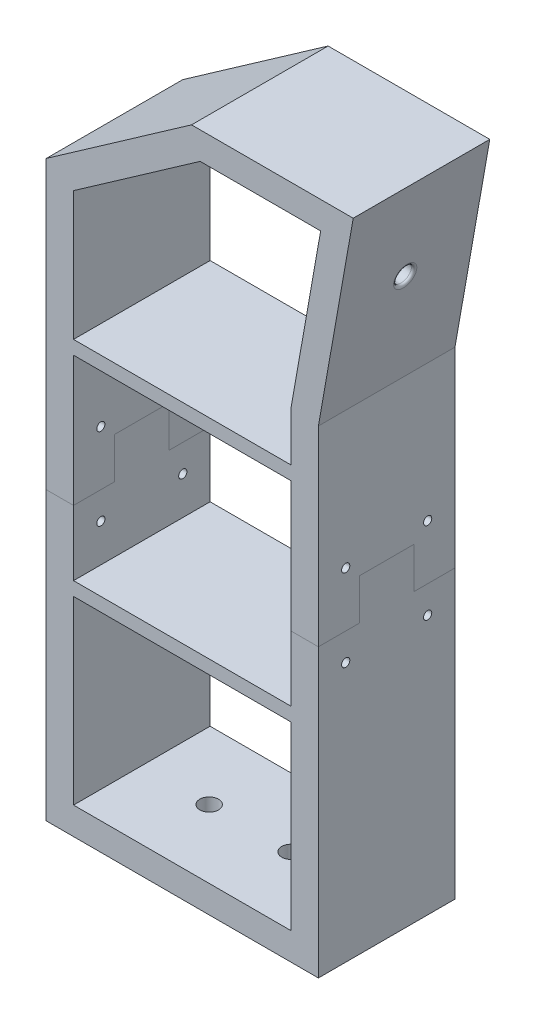
from build123d import *

# Parameters (mm, degrees)
BOSS_EXTRUDE1_DEPTH    = 50
SKETCH10_R             = 3.425
CUT_EXTRUDE5_DEPTH     = 10
SKETCH11_W             = 79.637459777
SKETCH11_H             = 5
BOSS_EXTRUDE3_DEPTH    = 50
SKETCH14_R             = 3.2
CUT_EXTRUDE6_DEPTH     = 10
FILLET1_R              = 1
SPLIT1_SURFACE_1_BACK  = 277.151
SPLIT1_SURFACE_1_DEPTH = 554.302
SPLIT1_SURFACE_2_BACK  = 277.151
SPLIT1_SURFACE_2_DEPTH = 554.302
SKETCH16_R             = 1.5
CUT_EXTRUDE7_DEPTH     = 99.637459777
CUT_EXTRUDE8_REACH     = 278.151
SKETCH17_R             = 1.5


with BuildPart() as part:
    # Sketch2 → Boss-Extrude1 (new body)
    with BuildSketch(Plane.XY):
        Polygon((-40.506485759, 0), (59.130974018, 0), (59.130974018, 175), (71.870010435, 247.246665631), (12.687265519, 247.246665631), (-40.506485759, 210), align=None)
        Polygon((49.130974018, 175.874886635), (59.952474509, 237.246665631), (15.840253408, 237.246665631), (-30.506485759, 204.794329494), (-30.506485759, 10), (49.130974018, 10), align=None, mode=Mode.SUBTRACT)
    extrude(amount=BOSS_EXTRUDE1_DEPTH)

    # Sketch10 → Cut-Extrude5 (cut)
    with BuildSketch(Plane(origin=(0, 10, 0), x_dir=(1, 0, 0), z_dir=(0, 1, 0))):
        with Locations(Location((-5.851287133, -25, 0), (0, 0, 270))):
            Circle(SKETCH10_R)
        with Locations(Location((24.130974018, -25, 0), (0, 0, 270))):
            Circle(SKETCH10_R)
    extrude(amount=-CUT_EXTRUDE5_DEPTH, mode=Mode.SUBTRACT)

    # Sketch11 → Boss-Extrude3 (add)
    with BuildSketch(Plane.XY.offset(50)):
        with Locations((9.31224413, 155.135730726)):
            Rectangle(SKETCH11_W, SKETCH11_H)
        with Locations((9.31224413, 78.651297101)):
            Rectangle(SKETCH11_W, SKETCH11_H)
    extrude(amount=-BOSS_EXTRUDE3_DEPTH)

    # Sketch14 → Cut-Extrude6 (cut)
    with BuildSketch(Plane(origin=(27.42119444, -4.835096423, 0), x_dir=(0, 0, -1), z_dir=(0.9848077530122082, -0.17364817766693028, 0))):
        with Locations(Location((-25, 221.609342659, 0), (0, 0, 90))):
            Circle(SKETCH14_R)
    extrude(amount=-CUT_EXTRUDE6_DEPTH, mode=Mode.SUBTRACT)

    # Fillet1
    fillet1_edges = [part.edges().sort_by_distance(p)[0] for p in [
        (65.347578778, 210.256117558, 25),
    ]]
    fillet(fillet1_edges, radius=FILLET1_R)


with BuildPart() as body_2:
    # Split1: the piece behind the surface
    add(part.part)
    # Split1 surface: a surface, the sketch's curves swept straight by 554.302 mm
    with BuildLine(Plane.ZY.offset(40.506485759).offset(-SPLIT1_SURFACE_1_BACK), mode=Mode.PRIVATE) as split1_surface_1_path:
        Line((0, 105), (15, 105))
        Line((15, 105), (15, 120))
        Line((15, 120), (35, 120))
        Line((35, 120), (35, 105))
        Line((35, 105), (50, 105))
    split1_surface_1 = Shell.extrude(split1_surface_1_path.wire(), (-1 * SPLIT1_SURFACE_1_DEPTH, 0 * SPLIT1_SURFACE_1_DEPTH, 0 * SPLIT1_SURFACE_1_DEPTH))
    split(bisect_by=split1_surface_1, keep=Keep.BOTTOM)

    # Sketch16 → Cut-Extrude7 (cut)
    with BuildSketch(Plane.ZY.offset(40.506485759)):
        with Locations(Location((10, 95, 0), (0, 0, 270))):
            Circle(SKETCH16_R)
        with Locations(Location((40, 95, 0), (0, 0, 180))):
            Circle(SKETCH16_R)
    extrude(amount=-CUT_EXTRUDE7_DEPTH, mode=Mode.SUBTRACT)


with BuildPart() as part_1:
    add(part.part)

    # Split1: split by a surface, the side it looks to stays
    # Split1 surface: a surface, the sketch's curves swept straight by 554.302 mm
    with BuildLine(Plane.ZY.offset(40.506485759).offset(-SPLIT1_SURFACE_2_BACK), mode=Mode.PRIVATE) as split1_surface_2_path:
        Line((0, 105), (15, 105))
        Line((15, 105), (15, 120))
        Line((15, 120), (35, 120))
        Line((35, 120), (35, 105))
        Line((35, 105), (50, 105))
    split1_surface_2 = Shell.extrude(split1_surface_2_path.wire(), (-1 * SPLIT1_SURFACE_2_DEPTH, 0 * SPLIT1_SURFACE_2_DEPTH, 0 * SPLIT1_SURFACE_2_DEPTH))
    split(bisect_by=split1_surface_2, keep=Keep.TOP)

    # Cut-Extrude8: up to this face of the body (flat: up to its plane)
    cut_extrude8_end = Plane(part_1.part.faces().sort_by_distance((59.130974018, 142.578125, 25))[0])
    # Sketch17 → Cut-Extrude8 (cut, up to the picked face)
    with BuildSketch(Plane.ZY.offset(40.506485759), mode=Mode.PRIVATE) as cut_extrude8_sk1:
        with Locations(Location((40, 125, 0), (0, 0, 270))):
            Circle(SKETCH17_R)
    cut_extrude8_tool1 = split(extrude(cut_extrude8_sk1.sketch, amount=-CUT_EXTRUDE8_REACH, mode=Mode.PRIVATE), bisect_by=cut_extrude8_end, keep=Keep.BOTH, mode=Mode.PRIVATE)
    # Sketch17 → Cut-Extrude8 (cut, up to the picked face)
    with BuildSketch(Plane.ZY.offset(40.506485759), mode=Mode.PRIVATE) as cut_extrude8_sk2:
        with Locations(Location((10, 125, 0), (0, 0, 270))):
            Circle(SKETCH17_R)
    cut_extrude8_tool2 = split(extrude(cut_extrude8_sk2.sketch, amount=-CUT_EXTRUDE8_REACH, mode=Mode.PRIVATE), bisect_by=cut_extrude8_end, keep=Keep.BOTH, mode=Mode.PRIVATE)
    add(cut_extrude8_tool1.solids().sort_by(Axis((-40.506486, 125, 40), (1, 0, 0)))[0], mode=Mode.SUBTRACT)
    add(cut_extrude8_tool2.solids().sort_by(Axis((-40.506486, 125, 10), (1, 0, 0)))[0], mode=Mode.SUBTRACT)


solid = Compound([body_2.part, part_1.part])
